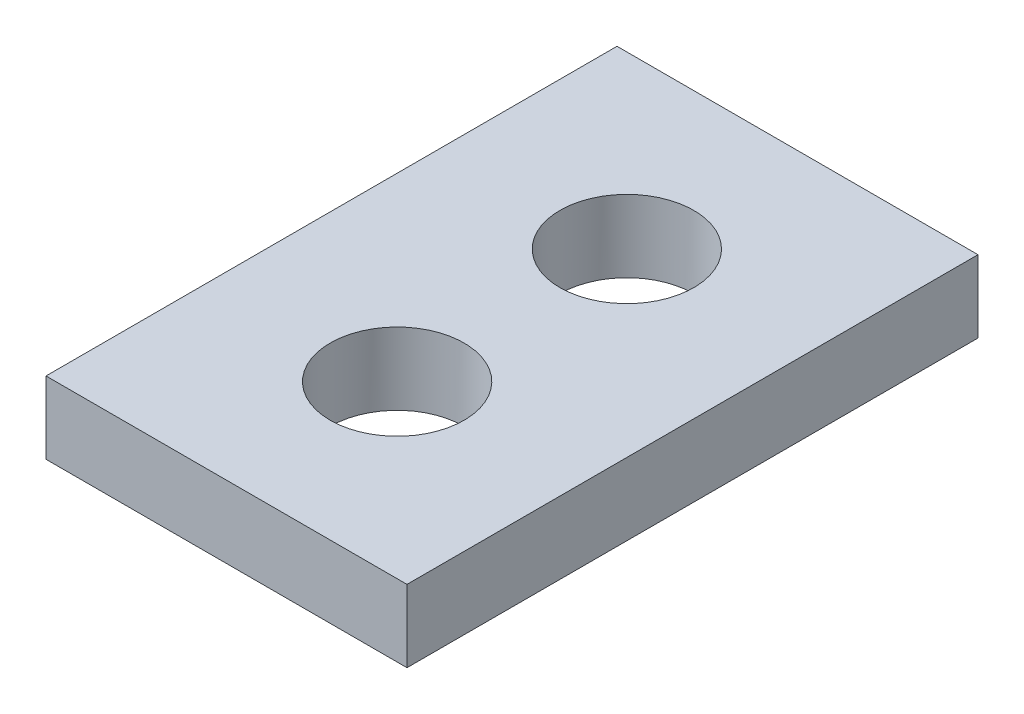
from build123d import *

# Parameters (mm, degrees)
SKETCH1_W           = 13.75
SKETCH1_H           = 21.75
BOSS_EXTRUDE1_DEPTH = 2.75
SKETCH2_R           = 2.55
CUT_EXTRUDE1_DEPTH  = 10


with BuildPart() as part:
    # Sketch1 → Boss-Extrude1 (new body)
    with BuildSketch(Plane(origin=(0, 0, 0), x_dir=(1, 0, 0), z_dir=(0, 1, 0))):
        Rectangle(SKETCH1_W, SKETCH1_H)
    extrude(amount=BOSS_EXTRUDE1_DEPTH)

    # Sketch2 → Cut-Extrude1 (cut)
    with BuildSketch(Plane(origin=(0, 2.75, 0), x_dir=(1, 0, 0), z_dir=(0, 1, 0))):
        with Locations((0, 4.375)):
            Circle(SKETCH2_R)
        with Locations((0, -4.375)):
            Circle(SKETCH2_R)
    extrude(amount=-CUT_EXTRUDE1_DEPTH, mode=Mode.SUBTRACT)


solid = part.part
